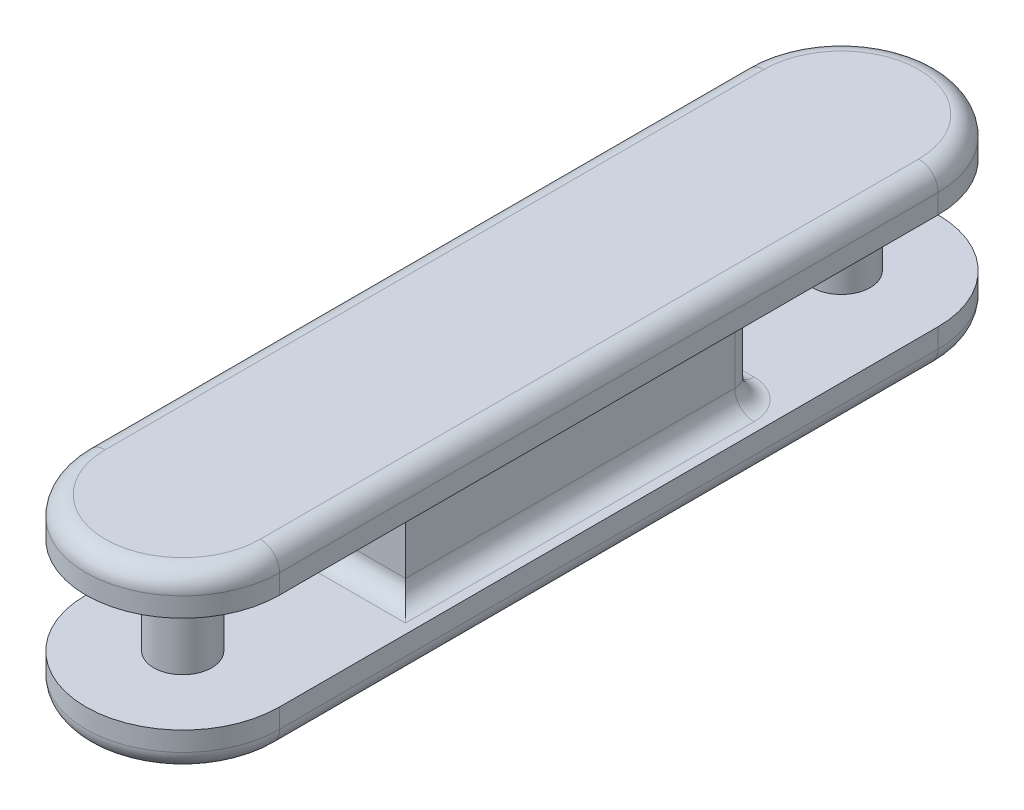
from build123d import *

# Parameters (mm, degrees)
EXTRUDE_1_DEPTH = 20
EXTRUDE_2_DEPTH = 20
SKETCH_3_R      = 15
SKETCH_3_W      = 70
SKETCH_3_H      = 180
EXTRUDE_3_DEPTH = 90
FILLET_1_R      = 10
FILLET_2_R      = 10


with BuildPart() as part:
    # 草圖1 → 填料-伸長1 (new body)
    with BuildSketch(Plane(origin=(0, 25, 0), x_dir=(1, 0, 0), z_dir=(0, 1, 0))):
        with BuildLine():
            Line((-50, 170), (-50, -170))
            ThreePointArc((-50, -170), (0, -220), (50, -170))
            Line((50, -170), (50, 170))
            ThreePointArc((50, 170), (0, 220), (-50, 170))
        make_face()
    extrude(amount=EXTRUDE_1_DEPTH)



with BuildPart() as body_2:
    # 草圖2 → 填料-伸長2 (new body)
    with BuildSketch(Plane(origin=(0, -25, 0), x_dir=(1, 0, 0), z_dir=(0, 1, 0))):
        with BuildLine():
            Line((50, -170), (50, 170))
            ThreePointArc((50, 170), (0, 220), (-50, 170))
            Line((-50, 170), (-50, -170))
            ThreePointArc((-50, -170), (0, -220), (50, -170))
        make_face()
    extrude(amount=-EXTRUDE_2_DEPTH)


with BuildPart() as part_1:
    add(part.part)

    add(body_2.part)  # 填料-伸長3 merges body 2
    # 草圖3 → 填料-伸長3 (add)
    with BuildSketch(Plane(origin=(0, 45, 0), x_dir=(1, 0, 0), z_dir=(0, 1, 0))):
        with Locations((0, 170)):
            Circle(SKETCH_3_R)
        with Locations((0, -170)):
            Circle(SKETCH_3_R)
        Rectangle(SKETCH_3_W, SKETCH_3_H)
    extrude(amount=-EXTRUDE_3_DEPTH)

    # 圓角1
    fillet_1_edges = [part_1.edges().sort_by_distance(p)[0] for p in [
        (0, 45, -220),
        (-50, 45, 0),
        (0, -45, -220),
        (50, -45, 0),
        (0, -45, 220),
        (-50, -45, 0),
        (0, 45, 220),
        (50, 45, 0),
    ]]
    fillet(fillet_1_edges, radius=FILLET_1_R)

    # 圓角2
    fillet_2_edges = [part_1.edges().sort_by_distance(p)[0] for p in [
        (35, -25, 0),
        (35, 0, -90),
        (0, -25, 90),
        (-35, -25, 0),
        (-35, 0, 90),
        (0, -25, -90),
        (-35, 0, -90),
        (35, 25, 0),
        (0, 25, 90),
        (-35, 25, 0),
        (0, 25, -90),
    ]]
    fillet(fillet_2_edges, radius=FILLET_2_R)


solid = part_1.part
